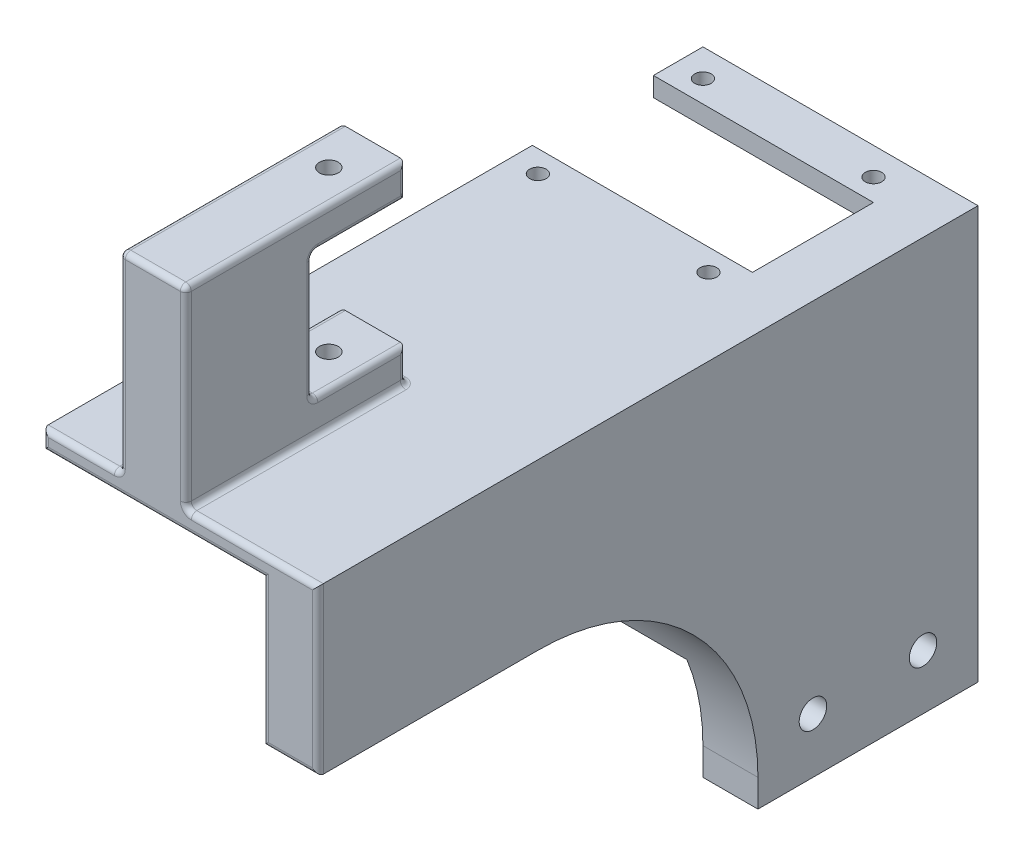
from build123d import *

# Parameters (mm, degrees)
SKETCH1_W               = 40
SKETCH1_H               = 55
SKETCH1_H_2             = 20
SKETCH1_R               = 2.5
BOSS_EXTRUDE1_DEPTH     = 10
SKETCH3_W               = 40
SKETCH3_H               = 10
BOSS_EXTRUDE2_DEPTH     = 40
SKETCH4_W               = 9
SKETCH4_H               = 3.5
BOSS_EXTRUDE3_DEPTH     = 40
SKETCH5_R               = 1.5
CUT_EXTRUDE1_DEPTH      = 3.5
SKETCH7_W               = 40
SKETCH7_H               = 3.5
BOSS_EXTRUDE4_DEPTH     = 80
SKETCH8_W               = 12
SKETCH8_H               = 40
BOSS_EXTRUDE5_DEPTH     = 35
SKETCH9_W               = 12
SKETCH9_H               = 23
CUT_EXTRUDE2_DEPTH      = 17
SKETCH10_R              = 1.7
CUT_EXTRUDE3_DEPTH      = 1
CUT_EXTRUDE3_DEPTH_BACK = 38.5
FILLET1_R               = 1
FILLET2_R               = 40


with BuildPart() as part:
    # Sketch1 → Boss-Extrude1 (new body)
    with BuildSketch(Plane(origin=(0, 0, 0), x_dir=(0, 0, -1), z_dir=(1, 0, 0))):
        with Locations((0, 27.5)):
            Rectangle(SKETCH1_W, SKETCH1_H)
        with Locations((0, -10)):
            Rectangle(SKETCH1_W, SKETCH1_H_2)
        with Locations((10, -10)):
            Circle(SKETCH1_R, mode=Mode.SUBTRACT)
        with Locations((-10, -10)):
            Circle(SKETCH1_R, mode=Mode.SUBTRACT)
    extrude(amount=BOSS_EXTRUDE1_DEPTH)

    # Sketch3 → Boss-Extrude2 (add)
    with BuildSketch(Plane.ZY):
        with Locations((0, 5)):
            Rectangle(SKETCH3_W, SKETCH3_H)
    extrude(amount=BOSS_EXTRUDE2_DEPTH)

    # Sketch4 → Boss-Extrude3 (add)
    with BuildSketch(Plane.ZY):
        with Locations((-15.5, 53.25)):
            Rectangle(SKETCH4_W, SKETCH4_H)
    boss_extrude3 = extrude(amount=BOSS_EXTRUDE3_DEPTH)

    # Sketch5 → Cut-Extrude1 (cut)
    with BuildSketch(Plane(origin=(0, 55, 0), x_dir=(1, 0, 0), z_dir=(0, 1, 0))):
        with Locations((-35, 15)):
            Circle(SKETCH5_R)
        with Locations((-4, 15)):
            Circle(SKETCH5_R)
    cut_extrude1 = extrude(amount=-CUT_EXTRUDE1_DEPTH, mode=Mode.SUBTRACT)

    # Mirror2: Boss-Extrude3, Cut-Extrude1 across plane
    add(boss_extrude3.mirror(Plane.XY))
    add(cut_extrude1.mirror(Plane.XY), mode=Mode.SUBTRACT)

    # Sketch7 → Boss-Extrude4 (add)
    with BuildSketch(Plane.XY.offset(20)):
        with Locations((-20, 53.25)):
            Rectangle(SKETCH7_W, SKETCH7_H)
        Polygon((10, 55), (0, 55), (0, 51.5), (0, 25), (10, 25), align=None)
    extrude(amount=BOSS_EXTRUDE4_DEPTH)

    # Sketch8 → Boss-Extrude5 (add)
    with BuildSketch(Plane(origin=(0, 55, 0), x_dir=(1, 0, 0), z_dir=(0, 1, 0))):
        with Locations((-20, -80)):
            Rectangle(SKETCH8_W, SKETCH8_H)
    extrude(amount=BOSS_EXTRUDE5_DEPTH)

    # Sketch9 → Cut-Extrude2 (cut)
    with BuildSketch(Plane(origin=(0, 0, 60), x_dir=(-1, 0, 0), z_dir=(0, 0, -1))):
        with Locations((20, 72.5)):
            Rectangle(SKETCH9_W, SKETCH9_H)
    extrude(amount=-CUT_EXTRUDE2_DEPTH, mode=Mode.SUBTRACT)

    # Sketch10 → Cut-Extrude3 (cut, two sides)
    with BuildSketch(Plane(origin=(0, 90, 0), x_dir=(1, 0, 0), z_dir=(0, 1, 0))) as cut_extrude3_sk:
        with Locations((-20, -68)):
            Circle(SKETCH10_R)
    extrude(amount=CUT_EXTRUDE3_DEPTH, mode=Mode.SUBTRACT)
    extrude(cut_extrude3_sk.sketch, amount=-CUT_EXTRUDE3_DEPTH_BACK, mode=Mode.SUBTRACT)

    # Fillet1
    fillet1_edges = [part.edges().sort_by_distance(p)[0] for p in [
        (-33, 55, 100),
        (-26, 55, 80),
        (-26, 87, 60),
        (-26, 72.5, 100),
        (-14, 55, 80),
        (-14, 72.5, 100),
        (-20, 55, 60),
        (-14, 87, 60),
        (-26, 90, 80),
        (-20, 90, 100),
        (-14, 90, 80),
        (-26, 58, 60),
        (-14, 58, 60),
        (-14, 72.5, 77),
        (-14, 61, 68.5),
        (-20, 84, 77),
        (-14, 84, 68.5),
        (-26, 72.5, 77),
        (-26, 84, 68.5),
        (-20, 61, 77),
        (-26, 61, 68.5),
        (-20, 51.5, 100),
        (0, 38.25, 100),
        (5, 25, 100),
        (10, 40, 100),
        (-2, 55, 100),
        (-40, 53.25, 100),
    ]]
    fillet(fillet1_edges, radius=FILLET1_R)

    # Fillet2
    fillet2_edges = [part.edges().sort_by_distance(p)[0] for p in [
        (5, 25, 20),
    ]]
    fillet(fillet2_edges, radius=FILLET2_R)


solid = part.part
